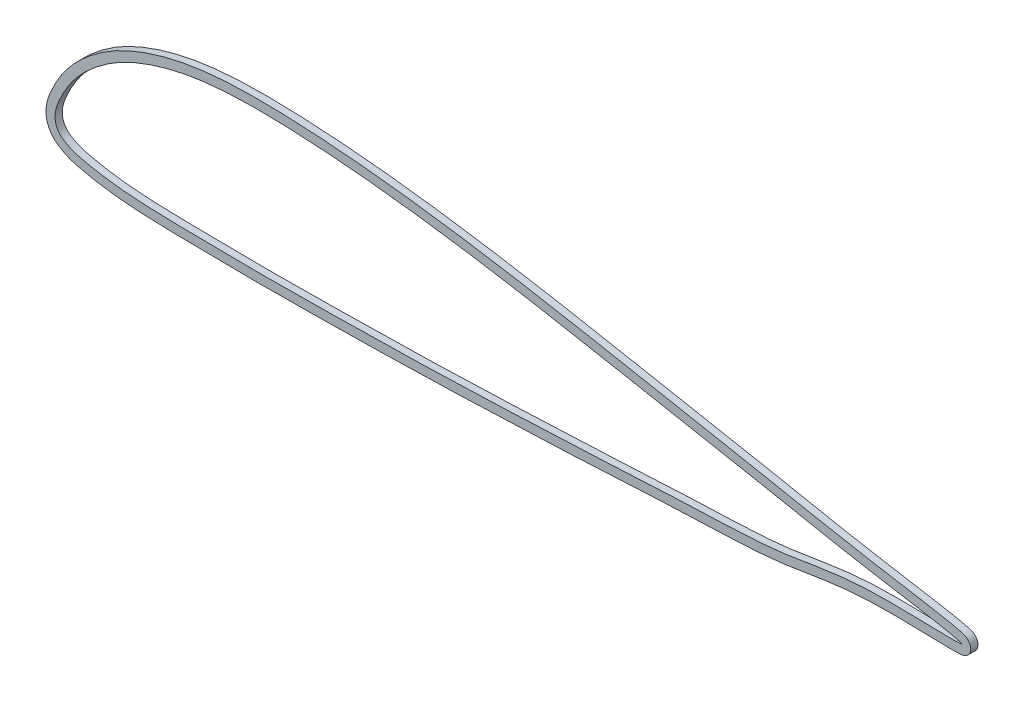
from build123d import *

# Parameters (mm, degrees)
BOSS_EXTRUDE5_DEPTH = 4


with BuildPart() as part:
    # Sketch14 → Boss-Extrude5 (new body)
    with BuildSketch(Plane.XY):
        with BuildLine():
            add(Edge.make_bspline(
                [(487.655960202, 11.318405494), (489.057345742, 11.274307088), (490.458694736, 11.223502071), (493.261668454, 11.172491917), (494.663294199, 11.172474124), (496.765968529, 11.21570387), (497.467049598, 11.234684854), (498.518266073, 11.28384861), (498.868320754, 11.303923101), (499.566981948, 11.359290501), (499.915613732, 11.39431783), (500.609707921, 11.497678655), (500.955526566, 11.567068634), (501.628644563, 11.76179327), (501.959680523, 11.888697076), (502.583893602, 12.200281319), (502.878455297, 12.384396991), (503.292683026, 12.705150521), (503.426882955, 12.820281106), (503.681093771, 13.061990922), (503.801137289, 13.18840946), (504.140533839, 13.584000122), (504.339366652, 13.869338866), (504.679672147, 14.485206879), (504.816356709, 14.80774951), (504.96995443, 15.30612626), (505.012711502, 15.475050834), (505.080946664, 15.818628807), (505.106383322, 15.99388865), (505.154768685, 16.516438462), (505.151044187, 16.864117887), (505.072114007, 17.558111702), (504.99569452, 17.904921465), (504.777198822, 18.565664453), (504.634895693, 18.883841126), (504.282338422, 19.494618163), (504.078004686, 19.776940138), (503.616567719, 20.298197689), (503.356364298, 20.538992186), (502.800604637, 20.963488398), (502.505007287, 21.148021964), (501.884699911, 21.471549738), (501.560426163, 21.610108093), (500.90823775, 21.854288157), (500.578103492, 21.961526619), (499.913875019, 22.161446398), (499.579728386, 22.253935027), (498.573962773, 22.519175308), (497.899111303, 22.680044049), (496.545941024, 22.989035302), (495.867444686, 23.136571253), (493.829222575, 23.568727446), (492.46819047, 23.844414214), (489.744642972, 24.38748125), (488.381658302, 24.652233544), (485.65210839, 25.161686726), (484.28543851, 25.405801638), (481.548325648, 25.872901876), (480.177883366, 26.095891121), (473.326496678, 27.215455853), (467.852467814, 28.15082898), (459.642918976, 29.561882542), (456.906781355, 30.034314365), (451.435002719, 30.981906735), (448.699499739, 31.457825758), (443.23090229, 32.422897985), (440.497825304, 32.912147255), (435.035625478, 33.912372875), (432.30651637, 34.42342468), (424.123599243, 35.980813058), (418.674469332, 37.052830144), (410.503251995, 38.674551463), (407.779743238, 39.216412755), (402.331137981, 40.291260985), (399.606104468, 40.824599971), (385.977365395, 43.471332694), (375.061991228, 45.519507154), (358.69044817, 48.600254465), (353.233351031, 49.627639072), (342.321476923, 51.695376388), (336.86654273, 52.734850335), (320.502102166, 55.855295574), (309.593060059, 57.938861785), (287.76264296, 62.037062073), (276.841108038, 64.050802261), (254.967887007, 67.909758801), (244.015871377, 69.753133352), (222.065201268, 73.179204226), (211.06535758, 74.763392059), (189.01154193, 77.595726379), (177.97504227, 78.841246378), (161.401475463, 80.374749852), (155.873809408, 80.829986965), (144.811484387, 81.616051176), (139.276755732, 81.945638456), (128.198683592, 82.451547645), (122.655561256, 82.631803995), (111.55728515, 82.778266922), (106.001942742, 82.741117487), (97.654986726, 82.437345742), (94.868844726, 82.294980289), (89.297076904, 81.90689376), (86.523252153, 81.661972991), (81.004088061, 81.051951721), (78.258752, 80.686837385), (72.800788986, 79.818609233), (70.088309165, 79.314874665), (62.002704126, 77.584981925), (56.681095537, 76.141475481), (48.81402473, 73.489588464), (46.210625124, 72.525645292), (42.339443835, 70.936630246), (41.054817626, 70.382625297), (38.498628684, 69.219500691), (37.22977154, 68.611395377), (33.481888285, 66.712967872), (31.052552079, 65.341880762), (26.333532261, 62.387021661), (24.042298843, 60.805609957), (20.701510431, 58.287194547), (19.604531129, 57.42241602), (17.985821809, 56.084494462), (17.450708529, 55.631733562), (16.389648808, 54.712251059), (15.863005288, 54.244883212), (14.30400702, 52.827422619), (13.291593842, 51.861881205), (11.324013896, 49.887058782), (10.369780561, 48.877064577), (7.615008953, 45.764618376), (5.92921351, 43.574496169), (3.574078266, 40.156704494), (2.815783522, 38.997001785), (1.367086738, 36.625722385), (0.680060645, 35.411566273), (-0.617873672, 32.925095561), (-1.2352554, 31.654311799), (-2.415357116, 29.100818319), (-2.969257054, 27.811709961), (-3.916515974, 25.178597103), (-4.311697214, 23.835215715), (-4.655937564, 22.104787468), (-4.717237652, 21.756120826), (-4.823197273, 21.05309739), (-4.867918813, 20.697780797), (-4.973621198, 19.634163877), (-5.006871046, 18.925845439), (-4.990776625, 17.510894046), (-4.941458988, 16.804260548), (-4.796476607, 15.745759304), (-4.735953973, 15.391792921), (-4.591172613, 14.69336086), (-4.506937792, 14.348609555), (-4.219148002, 13.327581283), (-3.980773525, 12.664429756), (-3.551874045, 11.696593701), (-3.396966069, 11.378483102), (-3.062345349, 10.751612223), (-2.881778735, 10.441671205), (-2.30811999, 9.535425877), (-1.885925947, 8.96562897), (-0.967849798, 7.889735804), (-0.471955057, 7.383650466), (0.327472831, 6.672574339), (0.604048063, 6.443305953), (1.167234748, 6.006995113), (1.454636661, 5.798947904), (2.331418138, 5.20017132), (2.935599742, 4.835200805), (4.164610815, 4.141191679), (4.786966915, 3.80784885), (6.050983223, 3.17475666), (6.693285487, 2.876124619), (8.005897853, 2.327600436), (8.66933459, 2.082627212), (10.003803105, 1.641383411), (10.675448214, 1.444211692), (12.024429013, 1.080122072), (12.701775926, 0.913263841), (14.058646027, 0.591117492), (14.73798333, 0.434841116), (16.778447818, -0.020948931), (18.142104011, -0.307017202), (22.242345771, -1.115921383), (24.988114649, -1.589934465), (30.507060969, -2.392243714), (33.280098417, -2.721284155), (38.846818659, -3.269604592), (41.637856935, -3.48845808), (47.215189514, -3.845266785), (50.004302693, -3.983657291), (58.372475347, -4.324232887), (63.952423747, -4.446824891), (72.322838068, -4.586685122), (75.113041156, -4.627486808), (80.69349026, -4.705246606), (83.483728943, -4.742861234), (97.43504982, -4.919521656), (108.596565542, -5.019750034), (125.340903019, -4.985294679), (130.922752368, -4.937678719), (142.086934374, -4.799172138), (147.669214833, -4.712955224), (164.415925678, -4.465992187), (175.580654247, -4.303598113), (192.323205532, -3.967831582), (197.903275802, -3.839774996), (209.061303901, -3.539974562), (214.639316672, -3.369366957), (231.371196365, -2.812901894), (242.522957106, -2.383486596), (264.825109644, -1.496344986), (275.975215288, -1.032700753), (292.696425049, -0.255571454), (298.269454487, 0.018096149), (309.413943863, 0.597890081), (314.985536789, 0.901266094), (326.129293738, 1.496207305), (331.701398368, 1.789000819), (342.848191595, 2.321148943), (348.422942695, 2.559210967), (359.575362148, 2.975003461), (365.152845765, 3.156554455), (373.515433981, 3.504101871), (376.302391937, 3.631769114), (381.874409256, 3.926368289), (384.659511857, 4.092406007), (390.226502859, 4.490954152), (393.00838245, 4.723646741), (397.17768372, 5.145443598), (398.566864426, 5.298169512), (401.343869464, 5.631672461), (402.731687137, 5.812587179), (406.893569152, 6.387821196), (409.66605702, 6.814743453), (415.209539084, 7.699478488), (417.980549455, 8.156956768), (423.524362154, 9.034853958), (426.297246242, 9.453582006), (431.847771594, 10.192655234), (434.625238724, 10.51660169), (440.185598394, 11.052291977), (442.968629001, 11.261180494), (448.539912065, 11.570964751), (451.328121341, 11.672753529), (459.699094037, 11.846902006), (465.287925325, 11.793772506), (473.674459933, 11.646086047), (476.470514465, 11.585627548), (480.664520625, 11.496504083), (482.062551035, 11.466209824), (484.159833281, 11.415874671), (484.858967106, 11.398274355), (486.257357305, 11.360539318), (486.955267432, 11.340454697), (487.655960202, 11.318405494)],
                knots=[0, 0, 0, 0, 0.00390625, 0.00390625, 0.0078125, 0.0078125, 0.009765625, 0.009765625, 0.010742188, 0.010742188, 0.01171875, 0.01171875, 0.012695313, 0.012695313, 0.013671875, 0.013671875, 0.014648438, 0.014648438, 0.015136719, 0.015136719, 0.015625, 0.015625, 0.016601563, 0.016601563, 0.017578125, 0.017578125, 0.018066406, 0.018066406, 0.018554688, 0.018554688, 0.01953125, 0.01953125, 0.020507813, 0.020507813, 0.021484375, 0.021484375, 0.022460938, 0.022460938, 0.0234375, 0.0234375, 0.024414063, 0.024414063, 0.025390625, 0.025390625, 0.026367188, 0.026367188, 0.02734375, 0.02734375, 0.029296875, 0.029296875, 0.03125, 0.03125, 0.03515625, 0.03515625, 0.0390625, 0.0390625, 0.04296875, 0.04296875, 0.046875, 0.046875, 0.0625, 0.0625, 0.0703125, 0.0703125, 0.078125, 0.078125, 0.0859375, 0.0859375, 0.09375, 0.09375, 0.109375, 0.109375, 0.1171875, 0.1171875, 0.125, 0.125, 0.15625, 0.15625, 0.171875, 0.171875, 0.1875, 0.1875, 0.21875, 0.21875, 0.25, 0.25, 0.28125, 0.28125, 0.3125, 0.3125, 0.34375, 0.34375, 0.359375, 0.359375, 0.375, 0.375, 0.390625, 0.390625, 0.40625, 0.40625, 0.4140625, 0.4140625, 0.421875, 0.421875, 0.4296875, 0.4296875, 0.4375, 0.4375, 0.453125, 0.453125, 0.4609375, 0.4609375, 0.46484375, 0.46484375, 0.46875, 0.46875, 0.4765625, 0.4765625, 0.484375, 0.484375, 0.48828125, 0.48828125, 0.490234375, 0.490234375, 0.4921875, 0.4921875, 0.49609375, 0.49609375, 0.5, 0.5, 0.5078125, 0.5078125, 0.51171875, 0.51171875, 0.515625, 0.515625, 0.51953125, 0.51953125, 0.5234375, 0.5234375, 0.52734375, 0.52734375, 0.528320313, 0.528320313, 0.529296875, 0.529296875, 0.53125, 0.53125, 0.533203125, 0.533203125, 0.534179688, 0.534179688, 0.53515625, 0.53515625, 0.537109375, 0.537109375, 0.538085938, 0.538085938, 0.5390625, 0.5390625, 0.541015625, 0.541015625, 0.54296875, 0.54296875, 0.543945313, 0.543945313, 0.544921875, 0.544921875, 0.546875, 0.546875, 0.548828125, 0.548828125, 0.55078125, 0.55078125, 0.552734375, 0.552734375, 0.5546875, 0.5546875, 0.556640625, 0.556640625, 0.55859375, 0.55859375, 0.5625, 0.5625, 0.5703125, 0.5703125, 0.578125, 0.578125, 0.5859375, 0.5859375, 0.59375, 0.59375, 0.609375, 0.609375, 0.6171875, 0.6171875, 0.625, 0.625, 0.65625, 0.65625, 0.671875, 0.671875, 0.6875, 0.6875, 0.71875, 0.71875, 0.734375, 0.734375, 0.75, 0.75, 0.78125, 0.78125, 0.8125, 0.8125, 0.828125, 0.828125, 0.84375, 0.84375, 0.859375, 0.859375, 0.875, 0.875, 0.890625, 0.890625, 0.8984375, 0.8984375, 0.90625, 0.90625, 0.9140625, 0.9140625, 0.91796875, 0.91796875, 0.921875, 0.921875, 0.9296875, 0.9296875, 0.9375, 0.9375, 0.9453125, 0.9453125, 0.953125, 0.953125, 0.9609375, 0.9609375, 0.96875, 0.96875, 0.984375, 0.984375, 0.9921875, 0.9921875, 0.99609375, 0.99609375, 0.998046875, 0.998046875, 1, 1, 1, 1], degree=3))
        make_face()
        with BuildLine():
            add(Edge.make_bspline(
                [(7.866428189, 37.560085444), (6.938591531, 36.171566471), (5.205494886, 33.388345671), (2.848098091, 28.674695825), (0.848747163, 24.133543154), (-0.107746476, 19.668256316), (0.04229169, 16.149642334), (1.236182063, 12.921845427), (3.416883643, 10.358060049), (6.495262055, 8.523106886), (10.127448243, 6.709317186), (14.980640459, 5.475978741), (21.138062661, 4.15286774), (28.305200826, 2.911658294), (36.217291445, 1.959520211), (44.034947677, 1.334120773), (53.011370152, 0.862691356), (61.897859117, 0.59322565), (71.531938589, 0.422867633), (80.066702423, 0.303091928), (88.69121587, 0.189140044), (96.777462409, 0.10088258), (106.276096056, 0.023009938), (116.035852959, -0.012293936), (127.332975975, 0.024689451), (137.665890196, 0.139932701), (148.255486382, 0.29637314), (157.184877056, 0.427740207), (165.598027616, 0.553110889), (173.300774394, 0.674971798), (181.194391154, 0.811797963), (188.83204481, 0.960506401), (198.265588962, 1.169515988), (207.316113689, 1.411330557), (216.537698653, 1.695410287), (223.450553442, 1.925923576), (231.979319172, 2.227308135), (241.259764139, 2.575386953), (251.858473678, 2.990400519), (261.45540833, 3.37510163), (269.185495433, 3.696346467), (277.288264205, 4.043936213), (286.856508579, 4.471363696), (297.411514353, 4.979626029), (307.253260404, 5.491569809), (315.786058687, 5.9504901), (326.138738132, 6.505634779), (338.722591283, 7.149538403), (351.799027155, 7.706123882), (365.963725519, 8.188608845), (381.325737555, 8.814536841), (396.927202205, 9.953910024), (412.041731394, 12.210907367), (425.264325471, 14.464252943), (439.17413754, 16.114742804), (452.74352491, 16.818636795), (465.767026362, 16.813799081), (477.382967159, 16.566779325), (487.893099973, 16.345651072), (494.045443438, 16.078970503), (503.199535964, 16.482847328), (486.734086077, 19.998065802), (476.567739048, 21.577355275), (455.999670421, 25.109629602), (436.363954131, 28.525755535), (419.345736354, 31.81039935), (404.141083587, 34.848652183), (391.306330775, 37.349577919), (376.820025473, 40.102729948), (362.655250182, 42.765384592), (347.931865553, 45.539086625), (334.611432618, 48.07372379), (320.011133365, 50.860108071), (303.893779286, 53.925708793), (285.232031152, 57.425508895), (268.670487025, 60.432091543), (253.817395036, 63.016551795), (240.49037061, 65.243431898), (223.849998754, 67.856762862), (206.582344437, 70.322494401), (190.05754678, 72.414474165), (175.958123105, 73.98696157), (163.323143638, 75.200014952), (151.918170622, 76.121191589), (141.136423807, 76.837588784), (130.116670867, 77.386447579), (119.540449473, 77.70557625), (109.531029417, 77.772960846), (100.873467484, 77.595445639), (93.185858745, 77.199271443), (86.7438297, 76.669666073), (80.882482078, 76.008254254), (74.397894009, 75.0510161), (68.046745376, 73.817699849), (61.497182478, 72.230215977), (55.447830013, 70.481551152), (49.016837863, 68.27302087), (42.861934298, 65.782634772), (36.989219458, 62.956699278), (31.662679073, 59.906825849), (26.642159371, 56.545568948), (21.617666438, 52.706946157), (16.915935985, 48.515040412), (12.103487325, 43.475517412), (9.349195933, 39.779065614), (7.866428189, 37.560085444)],
                knots=[0, 0, 0, 0, 0.004822611, 0.009466237, 0.015231509, 0.019108991, 0.02257025, 0.025251978, 0.028925546, 0.032025223, 0.035563018, 0.040627514, 0.046419072, 0.053790719, 0.061634086, 0.069447619, 0.076454745, 0.087614319, 0.095143344, 0.104306164, 0.112286184, 0.120074433, 0.127680587, 0.139742612, 0.148284674, 0.160334543, 0.169611186, 0.178896964, 0.186147478, 0.193931857, 0.201164312, 0.208967168, 0.216012436, 0.22843836, 0.235136622, 0.242679787, 0.248430852, 0.259804154, 0.26952348, 0.279089592, 0.28756609, 0.29188635, 0.30253195, 0.315250377, 0.322430529, 0.331017672, 0.339949824, 0.352397669, 0.367438295, 0.377780657, 0.393362982, 0.411883691, 0.422953059, 0.437520103, 0.450657122, 0.463402928, 0.476806952, 0.488154768, 0.497404518, 0.505985749, 0.509126356, 0.517095245, 0.531425852, 0.552982295, 0.571349333, 0.590628425, 0.602687765, 0.616234668, 0.628407797, 0.645313973, 0.657893144, 0.67171424, 0.684507032, 0.700856573, 0.719136182, 0.739388574, 0.749509076, 0.762713511, 0.778443572, 0.798196159, 0.813128906, 0.826587585, 0.83920129, 0.849816338, 0.859659598, 0.870433206, 0.881706481, 0.890240926, 0.899363375, 0.906731996, 0.912487614, 0.918044149, 0.923778657, 0.931430373, 0.936735046, 0.943254016, 0.949623986, 0.956381591, 0.96243368, 0.968448103, 0.974106728, 0.979885688, 0.986711773, 0.992293028, 1, 1, 1, 1], degree=3))
        make_face(mode=Mode.SUBTRACT)
    extrude(amount=BOSS_EXTRUDE5_DEPTH)


solid = part.part
